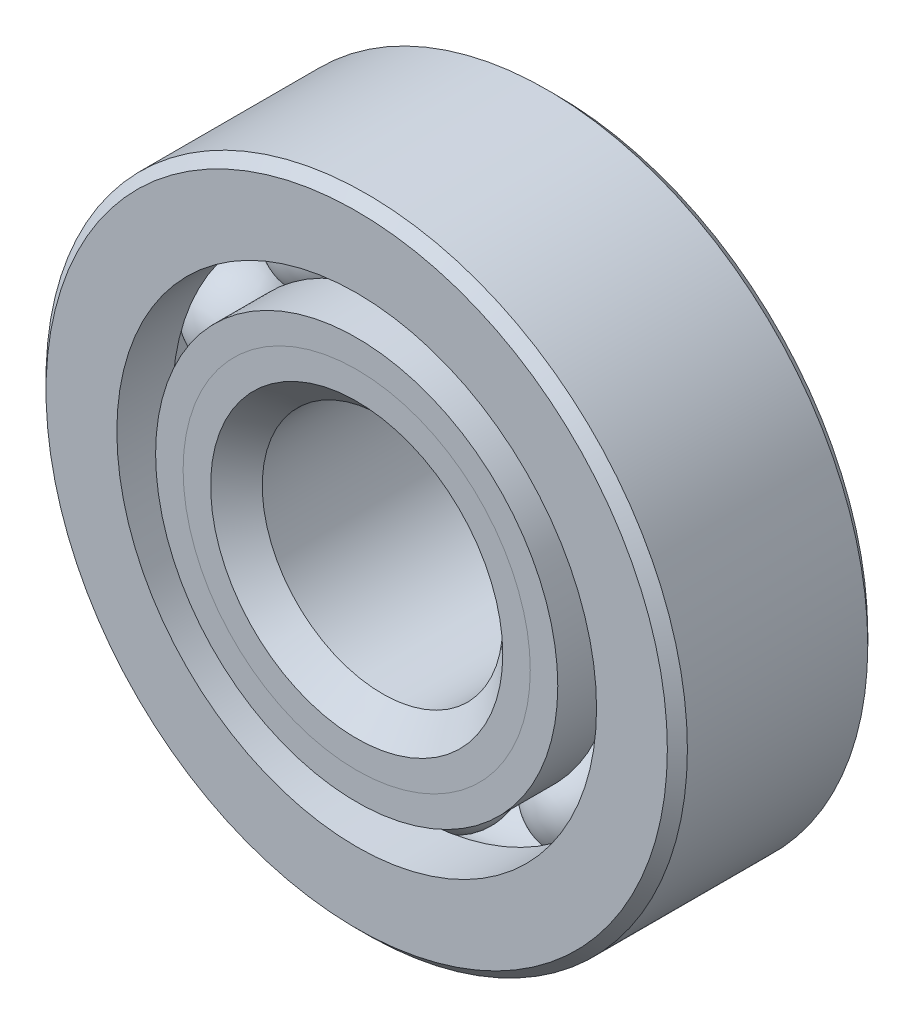
from build123d import *

# Parameters (mm, degrees)
CIRPATTERN1_COUNT = 10


with BuildPart() as part:
    # Sketch1 → Revolve1 (revolve)
    with BuildSketch(Plane(origin=(0, 0, 0), x_dir=(0, 0, -1), z_dir=(1, 0, 0))):
        with BuildLine():
            Line((1.7859375, 6.35), (-1.7859375, 6.35))
            Line((-1.7859375, 6.35), (-1.984375, 6.1515625))
            Line((-1.984375, 6.1515625), (-1.984375, 4.749416209))
            Line((-1.984375, 4.749416209), (-0.881944444, 4.749416209))
            ThreePointArc((-0.881944444, 4.749416209), (0, 5.327457467), (0.881944444, 4.749416209))
            Line((0.881944444, 4.749416209), (1.984375, 4.749416209))
            Line((1.984375, 4.749416209), (1.984375, 6.1515625))
            Line((1.984375, 6.1515625), (1.7859375, 6.35))
        make_face()
    revolve(axis=Axis((0, 0, 1.984375), (0, 0, -1)))


with BuildPart() as body_2:
    # Sketch2 → Revolve2 (revolve)
    with BuildSketch(Plane(origin=(0, 0, 0), x_dir=(0, 0, -1), z_dir=(1, 0, 0))):
        with BuildLine():
            Line((-1.984375, 3.981833791), (-0.881944444, 3.981833791))
            ThreePointArc((-0.881944444, 3.981833791), (-0.527247025, 3.561179682), (0, 3.403792533))
            Line((0, 3.403792533), (0, 2.892521266))
            Line((0, 2.892521266), (-1.439718738, 2.892521266))
            Line((-1.439718738, 2.892521266), (-1.984375, 3.437177529))
            Line((-1.984375, 3.437177529), (-1.984375, 3.981833791))
        make_face()
    revolve(axis=Axis((0, 0, 1.984375), (0, 0, -1)))


with BuildPart() as body_3:
    # Sketch3 → Revolve3 (revolve)
    with BuildSketch(Plane(origin=(0, 0, 0), x_dir=(0, 0, -1), z_dir=(1, 0, 0))):
        with BuildLine():
            Line((-1.984375, 3.437177529), (-1.439718738, 2.892521266))
            Line((-1.439718738, 2.892521266), (0, 2.892521266))
            Line((0, 2.892521266), (0, 3.403792533))
            ThreePointArc((0, 3.403792533), (0.527247025, 3.561179682), (0.881944444, 3.981833791))
            Line((0.881944444, 3.981833791), (1.984375, 3.981833791))
            Line((1.984375, 3.981833791), (1.984375, 2.5796875))
            Line((1.984375, 2.5796875), (1.7859375, 2.38125))
            Line((1.7859375, 2.38125), (-1.473103734, 2.38125))
            Line((-1.473103734, 2.38125), (-1.984375, 2.892521266))
            Line((-1.984375, 2.892521266), (-1.984375, 3.437177529))
        make_face()
    revolve(axis=Axis((0, 0, 1.984375), (0, 0, -1)))


with BuildPart() as body_4:
    # Sketch4 → Revolve4 (revolve)
    with BuildSketch(Plane(origin=(0, 0, 0), x_dir=(0, 0, -1), z_dir=(1, 0, 0))):
        with BuildLine():
            Line((-0.961832467, 4.365625), (0.961832467, 4.365625))
            ThreePointArc((0.961832467, 4.365625), (0, 5.327457467), (-0.961832467, 4.365625))
        make_face()
    revolve(axis=Axis((0, 4.365625, 0.961832467), (0, 0, -1)))


with BuildPart() as cirpattern1_1:
    # CirPattern1: pattern copy
    add(body_4.part.rotate(Axis((0, 0, -1.984375), (0, 0, 1)), 1 * 360 / CIRPATTERN1_COUNT))


with BuildPart() as cirpattern1_2:
    # CirPattern1: pattern copy
    add(body_4.part.rotate(Axis((0, 0, -1.984375), (0, 0, 1)), 2 * 360 / CIRPATTERN1_COUNT))


with BuildPart() as cirpattern1_3:
    # CirPattern1: pattern copy
    add(body_4.part.rotate(Axis((0, 0, -1.984375), (0, 0, 1)), 3 * 360 / CIRPATTERN1_COUNT))


with BuildPart() as cirpattern1_4:
    # CirPattern1: pattern copy
    add(body_4.part.rotate(Axis((0, 0, -1.984375), (0, 0, 1)), 4 * 360 / CIRPATTERN1_COUNT))


with BuildPart() as cirpattern1_5:
    # CirPattern1: pattern copy
    add(body_4.part.rotate(Axis((0, 0, -1.984375), (0, 0, 1)), 5 * 360 / CIRPATTERN1_COUNT))


with BuildPart() as cirpattern1_6:
    # CirPattern1: pattern copy
    add(body_4.part.rotate(Axis((0, 0, -1.984375), (0, 0, 1)), 6 * 360 / CIRPATTERN1_COUNT))


with BuildPart() as cirpattern1_7:
    # CirPattern1: pattern copy
    add(body_4.part.rotate(Axis((0, 0, -1.984375), (0, 0, 1)), 7 * 360 / CIRPATTERN1_COUNT))


with BuildPart() as cirpattern1_8:
    # CirPattern1: pattern copy
    add(body_4.part.rotate(Axis((0, 0, -1.984375), (0, 0, 1)), 8 * 360 / CIRPATTERN1_COUNT))


with BuildPart() as cirpattern1_9:
    # CirPattern1: pattern copy
    add(body_4.part.rotate(Axis((0, 0, -1.984375), (0, 0, 1)), 9 * 360 / CIRPATTERN1_COUNT))


solid = Compound([part.part, body_2.part, body_3.part, body_4.part, cirpattern1_1.part, cirpattern1_2.part, cirpattern1_3.part, cirpattern1_4.part, cirpattern1_5.part, cirpattern1_6.part, cirpattern1_7.part, cirpattern1_8.part, cirpattern1_9.part])
